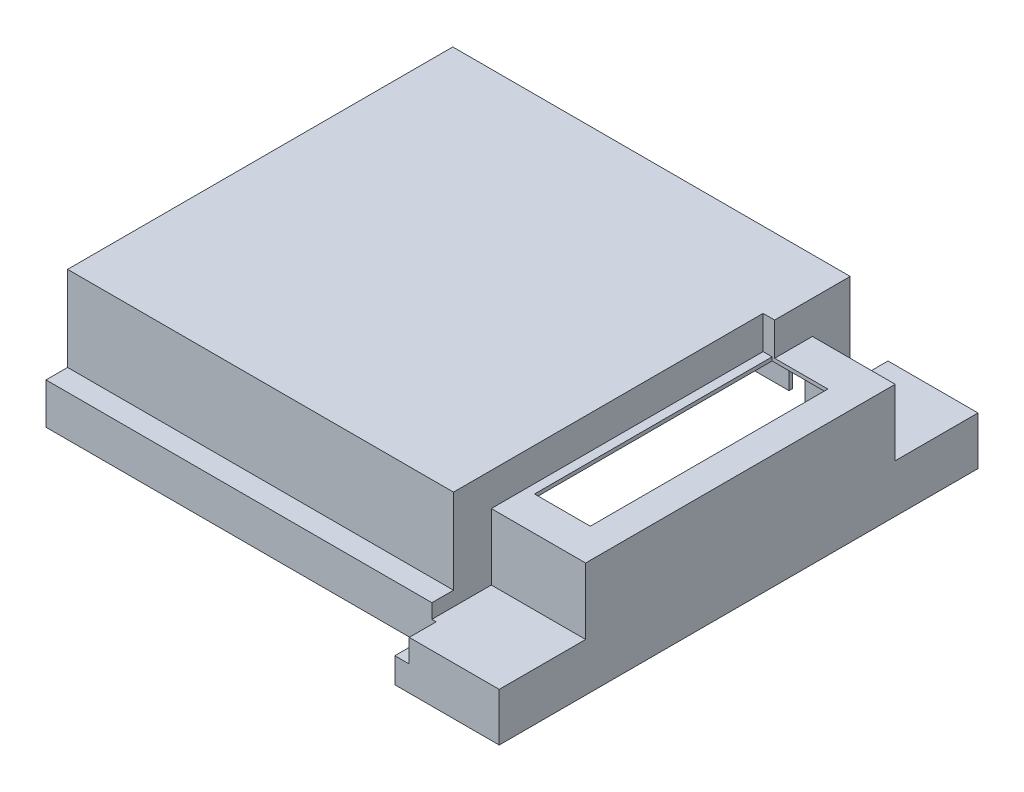
from build123d import *

# Parameters (mm, degrees)
HV_TOP_PANEL_DEPTH                   = 107.95
SKETCH10_W                           = 73.025
SKETCH10_H                           = 415.925
INTERFACE_WITH_BACK_COVER_DEPTH      = 78.74
SKETCH11_W                           = 334.01
SKETCH11_H                           = 19.05
INTEFACE_WITH_MOTOR_DISCONNECT_DEPTH = 74.93
CUT_EXTRUDE6_DEPTH                   = 87.63
SKETCH14_W                           = 10.16
SKETCH14_H                           = 239.7125
CUT_EXTRUDE3_DEPTH                   = 29.21
SHELL1_T                             = 3.175
SKETCH17_W                           = 39.6875
SKETCH17_H                           = 3.175
SKETCH17_W_2                         = 23.8125
OVERLAP_ON_LID_DEPTH                 = 12.7
LIP_DEPTH                            = 19.05
SKETCH18_W                           = 49.2125
SKETCH18_H                           = 209.55
MOTOR_DISCONNECT_DEPTH               = 7.62
SKETCH19_W                           = 44.45
SKETCH19_H                           = 105.664
SKETCH19_W_2                         = 171.45
SKETCH19_H_2                         = 79.375
LV_AND_HV_PANELS_DEPTH               = 7.62


with BuildPart() as part:
    # Sketch4 → HV Top Panel (new body)
    with BuildSketch(Plane(origin=(0, 0, 0), x_dir=(1, 0, 0), z_dir=(0, 1, 0))):
        Polygon((176.607773845, -221.387726412), (-167.562226155, -221.387726412), (-167.562226155, -219.800226412), (-167.562226155, 131.037273588), (176.607773845, 131.037273588), align=None)
    extrude(amount=HV_TOP_PANEL_DEPTH)

    # Sketch10 → Interface with Back Cover (add)
    with BuildSketch(Plane(origin=(0, 0, 0), x_dir=(1, 0, 0), z_dir=(0, 1, 0))):
        with Locations((213.120273845, -37.237726412)):
            Rectangle(SKETCH10_W, SKETCH10_H)
    extrude(amount=INTERFACE_WITH_BACK_COVER_DEPTH)

    # Sketch11 → Inteface with Motor Disconnect (cut)
    with BuildSketch(Plane(origin=(0, 107.95, 0), x_dir=(1, 0, 0), z_dir=(0, 1, 0))):
        with Locations((-0.557226155, -211.862726412)):
            Rectangle(SKETCH11_W, SKETCH11_H)
    extrude(amount=-INTEFACE_WITH_MOTOR_DISCONNECT_DEPTH, mode=Mode.SUBTRACT)

    # Sketch11_3 → Cut-Extrude6 (cut)
    with BuildSketch(Plane(origin=(0, 107.95, 0), x_dir=(1, 0, 0), z_dir=(0, 1, 0))):
        Polygon((166.447773845, -245.200226412), (249.632773845, -245.200226412), (249.632773845, -169.000226412), (176.607773845, -169.000226412), (176.607773845, -221.387726412), (166.447773845, -221.387726412), align=None)
        Polygon((166.447773845, -202.337726412), (166.447773845, -221.387726412), (176.607773845, -221.387726412), (176.607773845, -169.000226412), (166.447773845, -169.000226412), align=None)
        Polygon((176.607773845, 131.037273588), (176.607773845, 97.699773588), (249.632773845, 97.699773588), (249.632773845, 170.724773588), (176.607773845, 170.724773588), align=None)
    extrude(amount=-CUT_EXTRUDE6_DEPTH, mode=Mode.SUBTRACT)

    # Sketch14 → Cut-Extrude3 (cut)
    with BuildSketch(Plane(origin=(0, 107.95, 0), x_dir=(1, 0, 0), z_dir=(0, 1, 0))):
        with Locations((171.527773845, -49.143976412)):
            Rectangle(SKETCH14_W, SKETCH14_H)
    extrude(amount=-CUT_EXTRUDE3_DEPTH, mode=Mode.SUBTRACT)

    # Shell1
    shell1_openings = [part.faces().sort_by_distance(p)[0] for p in [
        (46.296622828, 0, 43.585658338),
    ]]
    offset(amount=SHELL1_T, openings=shell1_openings, kind=Kind.INTERSECTION)

    # Sketch17 → Overlap on Lid (add)
    with BuildSketch(Plane.ZY.offset(-173.432773845)):
        with Locations((-154.056023588, 1.5875)):
            Rectangle(SKETCH17_W, SKETCH17_H)
        with Locations((236.468976412, 1.5875)):
            Rectangle(SKETCH17_W_2, SKETCH17_H)
    extrude(amount=OVERLAP_ON_LID_DEPTH)

    # Sketch15 → Lip (add)
    with BuildSketch(Plane.XZ):
        Polygon((249.632773845, 245.200226412), (249.632773845, -170.724773588), (176.607773845, -170.724773588), (160.732773845, -170.724773588), (160.732773845, -173.899773588), (252.807773845, -173.899773588), (252.807773845, 248.375226412), (160.732773845, 248.375226412), (160.732773845, 245.200226412), (176.607773845, 245.200226412), align=None)
    extrude(amount=LIP_DEPTH)

    # Sketch18 → Motor Disconnect (cut)
    with BuildSketch(Plane(origin=(0, 81.915, 0), x_dir=(1, 0, 0), z_dir=(0, 1, 0))):
        with Locations((202.166523845, -37.237726412)):
            Rectangle(SKETCH18_W, SKETCH18_H)
    extrude(amount=-MOTOR_DISCONNECT_DEPTH, mode=Mode.SUBTRACT)

    # Sketch19 → LV and HV Panels (cut)
    with BuildSketch(Plane(origin=(0, 0, -134.212273588), x_dir=(-1, 0, 0), z_dir=(0, 0, -1))):
        with Locations((-151.207773845, 52.832)):
            Rectangle(SKETCH19_W, SKETCH19_H)
        with Locations((81.837226155, 39.6875)):
            Rectangle(SKETCH19_W_2, SKETCH19_H_2)
    extrude(amount=-LV_AND_HV_PANELS_DEPTH, mode=Mode.SUBTRACT)


solid = part.part
